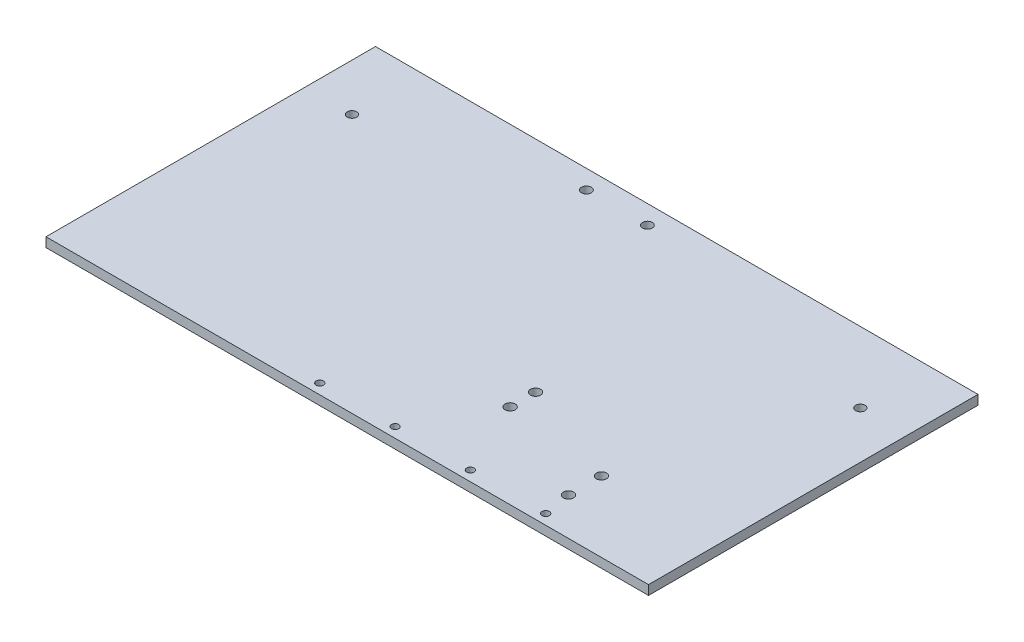
from build123d import *

# Parameters (mm, degrees)
SKETCH1_W           = 406.4
SKETCH1_H           = 222.25
BOSS_EXTRUDE1_DEPTH = 6.35
SKETCH2_R           = 3.302
SKETCH2_R_2         = 3.175
CUT_EXTRUDE1_DEPTH  = 6.35
SKETCH3_R           = 2.4638
CUT_EXTRUDE2_DEPTH  = 7.35
CUT_EXTRUDE3_REACH  = 8.35
SKETCH4_R           = 3.429


with BuildPart() as part:
    # Sketch1 → Boss-Extrude1 (new body)
    with BuildSketch(Plane(origin=(0, 0, 0), x_dir=(1, 0, 0), z_dir=(0, 1, 0))):
        Rectangle(SKETCH1_W, SKETCH1_H)
    extrude(amount=BOSS_EXTRUDE1_DEPTH)

    # Sketch2 → Cut-Extrude1 (cut)
    with BuildSketch(Plane(origin=(0, 6.35, 0), x_dir=(1, 0, 0), z_dir=(0, 1, 0))):
        with Locations((-48.26, 98.425)):
            Circle(SKETCH2_R)
        with Locations((-7.112, 98.425)):
            Circle(SKETCH2_R)
        with Locations((-171.45, 63.5)):
            Circle(SKETCH2_R_2)
        with Locations((171.45, 63.5)):
            Circle(SKETCH2_R_2)
    extrude(amount=-CUT_EXTRUDE1_DEPTH, mode=Mode.SUBTRACT)

    # Sketch3 → Cut-Extrude2 (cut, through all)
    with BuildSketch(Plane.XZ):
        with Locations((127, 104.267)):
            Circle(SKETCH3_R)
        with Locations((76.2, 104.267)):
            Circle(SKETCH3_R)
        with Locations((25.4, 104.267)):
            Circle(SKETCH3_R)
        with Locations((-25.4, 104.267)):
            Circle(SKETCH3_R)
    extrude(amount=-CUT_EXTRUDE2_DEPTH, mode=Mode.SUBTRACT)

    # Sketch4 → Cut-Extrude3 (cut, up to next)
    with BuildSketch(Plane.XZ, mode=Mode.PRIVATE) as cut_extrude3_sk1:
        with Locations((52.705, 36.83)):
            Circle(SKETCH4_R)
    cut_extrude3_tool1 = extrude(cut_extrude3_sk1.sketch, amount=-CUT_EXTRUDE3_REACH, mode=Mode.PRIVATE) & part.part
    add(cut_extrude3_tool1.solids().sort_by_distance((52.705, 0, 36.83))[0], mode=Mode.SUBTRACT)
    # Sketch4 → Cut-Extrude3 (cut, up to next)
    with BuildSketch(Plane.XZ, mode=Mode.PRIVATE) as cut_extrude3_sk2:
        with Locations((52.705, 53.975)):
            Circle(SKETCH4_R)
    cut_extrude3_tool2 = extrude(cut_extrude3_sk2.sketch, amount=-CUT_EXTRUDE3_REACH, mode=Mode.PRIVATE) & part.part
    add(cut_extrude3_tool2.solids().sort_by_distance((52.705, 0, 53.975))[0], mode=Mode.SUBTRACT)
    # Sketch4 → Cut-Extrude3 (cut, up to next)
    with BuildSketch(Plane.XZ, mode=Mode.PRIVATE) as cut_extrude3_sk3:
        with Locations((123.825, 63.5)):
            Circle(SKETCH4_R)
    cut_extrude3_tool3 = extrude(cut_extrude3_sk3.sketch, amount=-CUT_EXTRUDE3_REACH, mode=Mode.PRIVATE) & part.part
    add(cut_extrude3_tool3.solids().sort_by_distance((123.825, 0, 63.5))[0], mode=Mode.SUBTRACT)
    # Sketch4 → Cut-Extrude3 (cut, up to next)
    with BuildSketch(Plane.XZ, mode=Mode.PRIVATE) as cut_extrude3_sk4:
        with Locations((123.825, 85.725)):
            Circle(SKETCH4_R)
    cut_extrude3_tool4 = extrude(cut_extrude3_sk4.sketch, amount=-CUT_EXTRUDE3_REACH, mode=Mode.PRIVATE) & part.part
    add(cut_extrude3_tool4.solids().sort_by_distance((123.825, 0, 85.725))[0], mode=Mode.SUBTRACT)


solid = part.part
